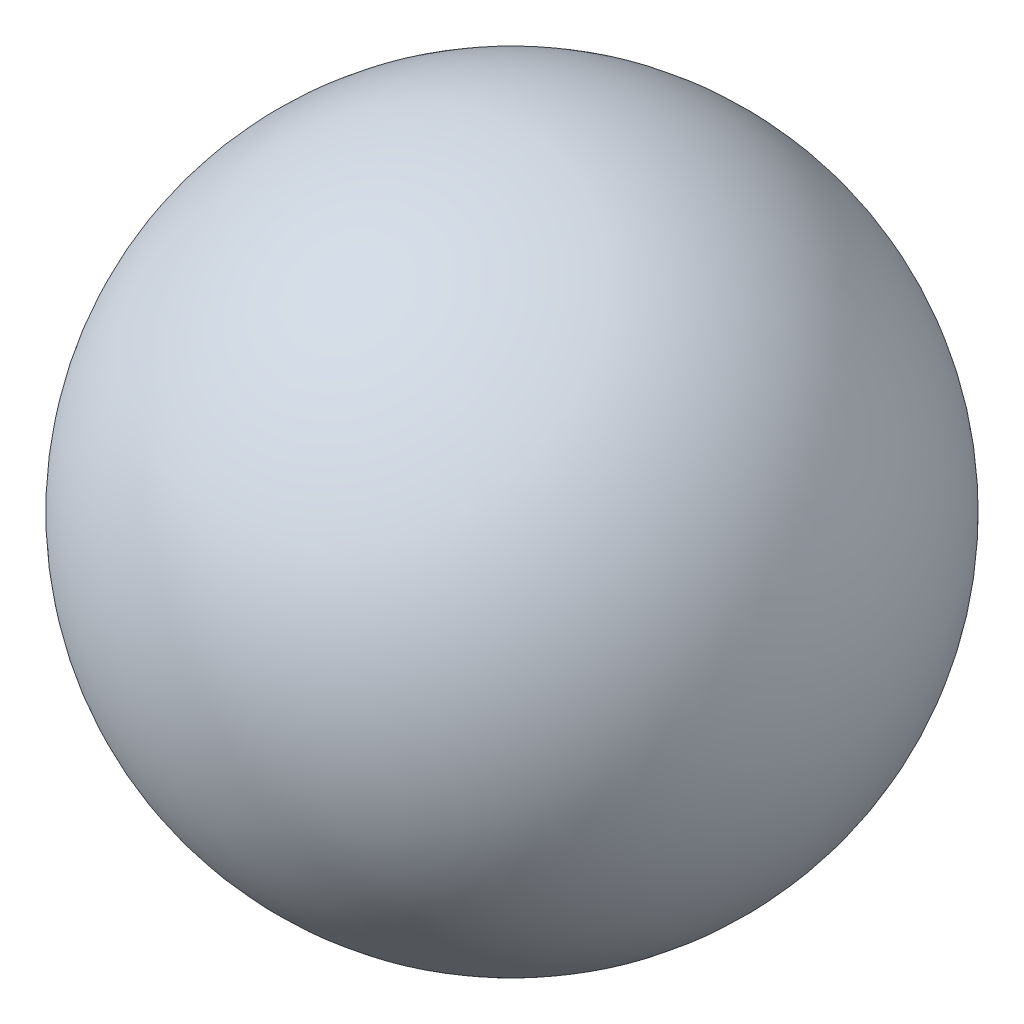
from build123d import *


with BuildPart() as part:
    # Esquisse2 → Révolution5 (revolve)
    with BuildSketch(Plane.XY):
        with BuildLine():
            Line((0, -22), (0, 22))
            ThreePointArc((0, 22), (22, 0), (0, -22))
        make_face()
    revolve(axis=Axis((0, -24.2, 0), (0, 1, 0)))


solid = part.part
